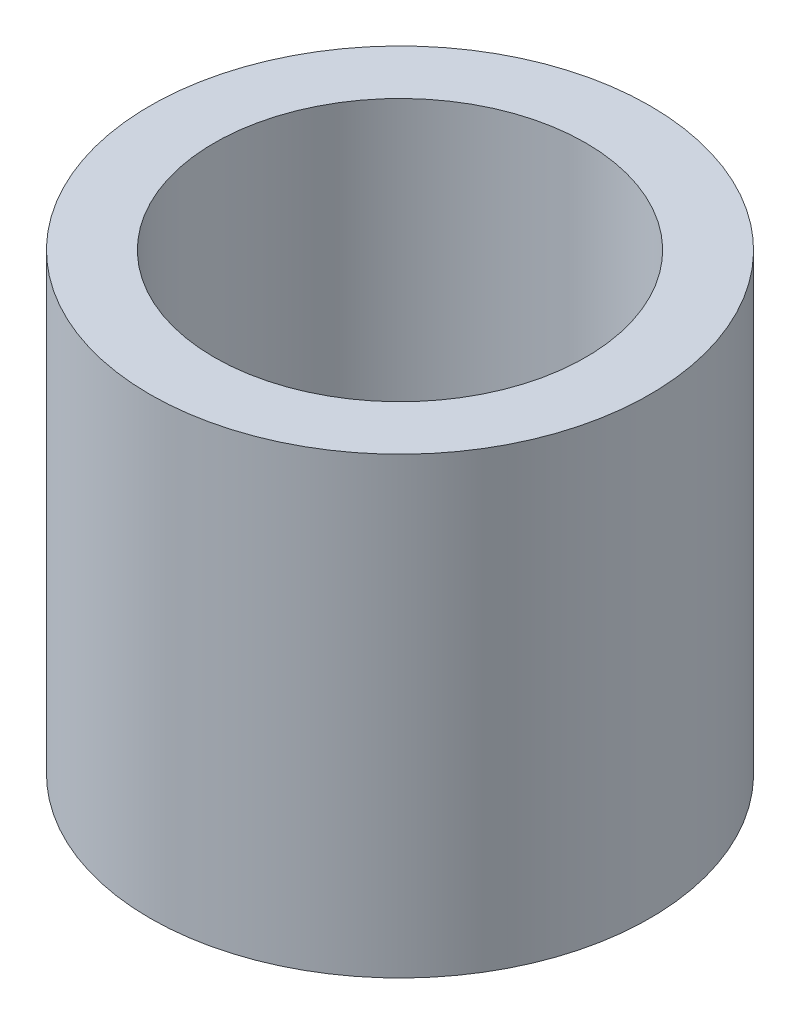
from build123d import *

# Parameters (mm, degrees)
SKETCH2_R           = 3.5
SKETCH2_R_2         = 2.6
BOSS_EXTRUDE1_DEPTH = 6.35


with BuildPart() as part:
    # Sketch2 → Boss-Extrude1 (new body)
    with BuildSketch(Plane(origin=(0, 0, 0), x_dir=(1, 0, 0), z_dir=(0, 1, 0))):
        Circle(SKETCH2_R)
        Circle(SKETCH2_R_2, mode=Mode.SUBTRACT)
    extrude(amount=BOSS_EXTRUDE1_DEPTH)


solid = part.part
